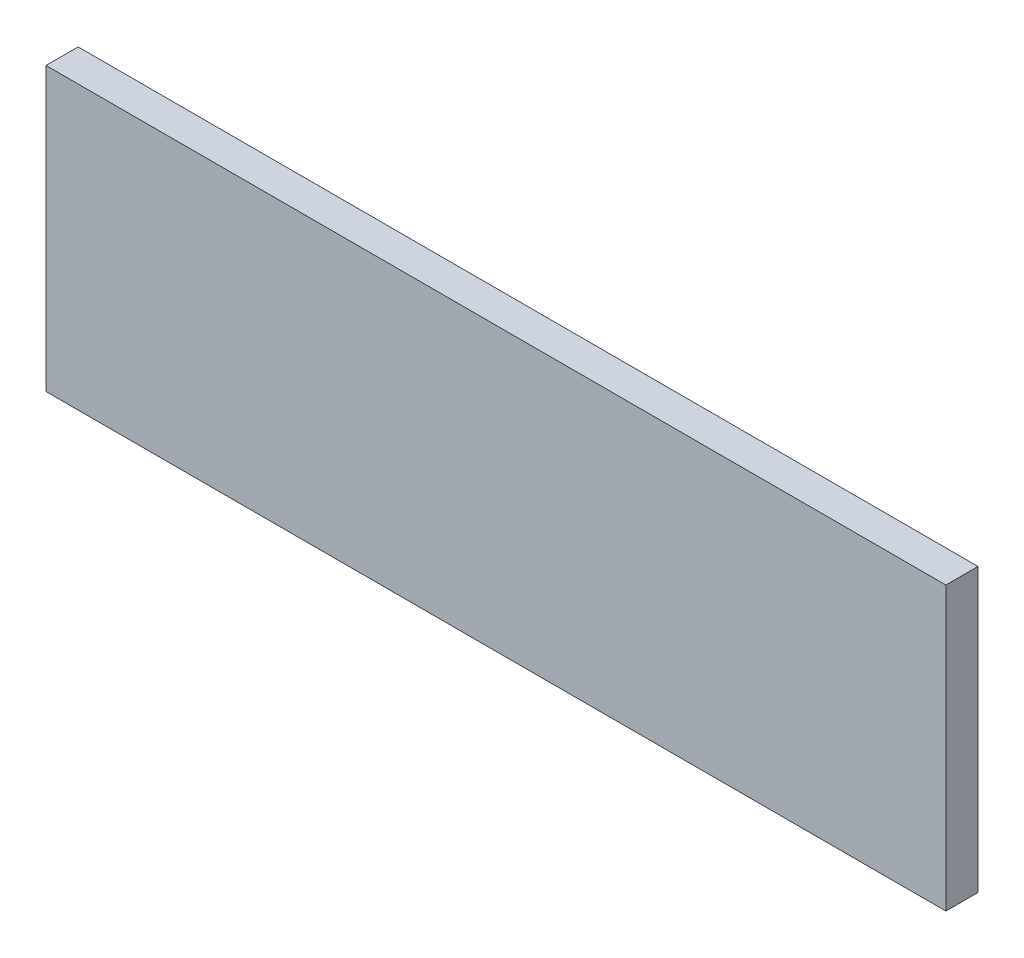
from build123d import *

# Parameters (mm, degrees)
SKETCH1_W           = 177.8
SKETCH1_H           = 55.8
BOSS_EXTRUDE1_DEPTH = 3.175


with BuildPart() as part:
    # Sketch1 → Boss-Extrude1 (new, symmetric)
    with BuildSketch(Plane.XY):
        Rectangle(SKETCH1_W, SKETCH1_H)
    extrude(amount=BOSS_EXTRUDE1_DEPTH, both=True)


solid = part.part
